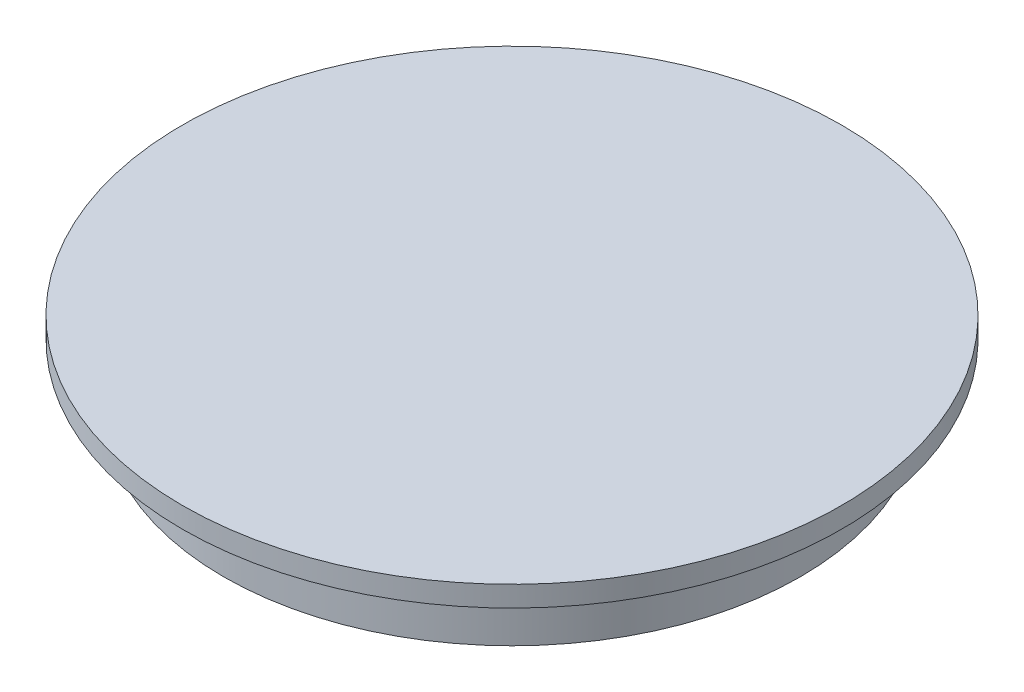
from build123d import *

# Parameters (mm, degrees)
SKETCH2_R          = 41.275
CUT_EXTRUDE1_DEPTH = 9.525


with BuildPart() as part:
    # Sketch1 → Revolve1 (revolve)
    with BuildSketch(Plane.XY):
        Polygon((0, 0), (-50.8, 0), (-50.8, -3.175), (-44.45, -3.175), (-44.45, -12.7), (0, -12.7), align=None)
    revolve(axis=Axis((0, -12.7, 0), (0, 1, 0)))

    # Sketch2 → Cut-Extrude1 (cut)
    with BuildSketch(Plane.XZ.offset(12.7)):
        Circle(SKETCH2_R)
    extrude(amount=-CUT_EXTRUDE1_DEPTH, mode=Mode.SUBTRACT)


solid = part.part
